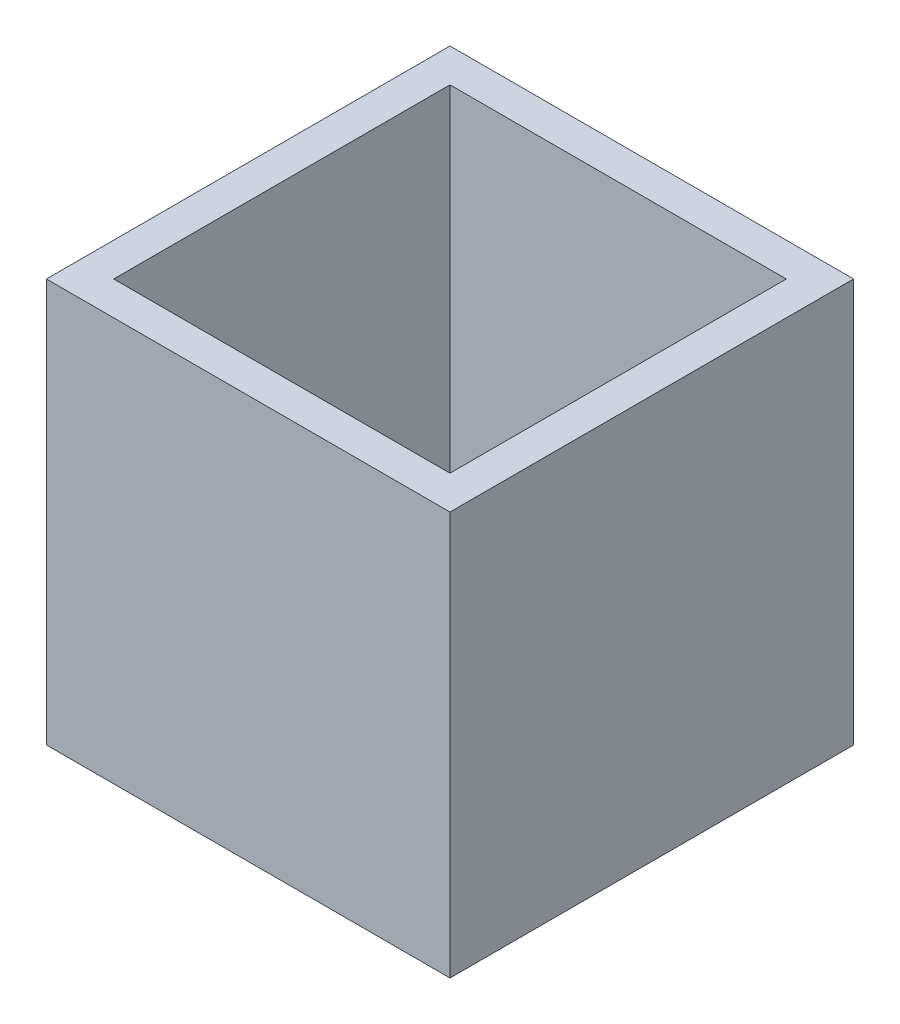
from build123d import *

# Parameters (mm, degrees)
SKETCH1_W           = 12
SKETCH1_H           = 12
BOSS_EXTRUDE1_DEPTH = 12
SKETCH2_W           = 10
SKETCH2_H           = 10
CUT_EXTRUDE1_DEPTH  = 13


with BuildPart() as part:
    # Sketch1 → Boss-Extrude1 (new body)
    with BuildSketch(Plane(origin=(0, 0, 0), x_dir=(1, 0, 0), z_dir=(0, 1, 0))):
        with Locations((6, 6)):
            Rectangle(SKETCH1_W, SKETCH1_H)
    extrude(amount=BOSS_EXTRUDE1_DEPTH)

    # Sketch2 → Cut-Extrude1 (cut, through all)
    with BuildSketch(Plane(origin=(0, 12, 0), x_dir=(1, 0, 0), z_dir=(0, 1, 0))):
        with Locations((6, 6)):
            Rectangle(SKETCH2_W, SKETCH2_H)
    extrude(amount=-CUT_EXTRUDE1_DEPTH, mode=Mode.SUBTRACT)


solid = part.part
